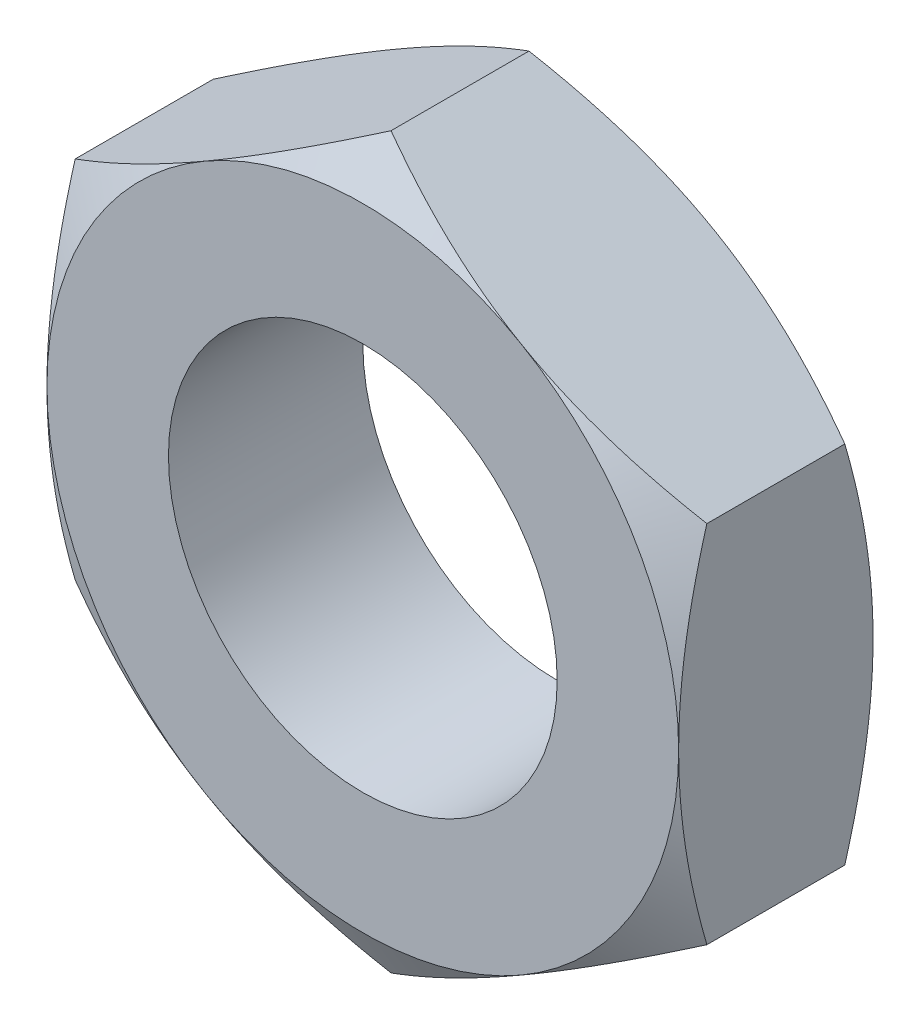
from build123d import *

# Parameters (mm, degrees)
SZKIC1_R                    = 4
DODANIE_WYCI_GNI_CIE1_DEPTH = 4


with BuildPart() as part:
    # Szkic1 → Dodanie-wyciągnięcie1 (new body)
    with BuildSketch(Plane.XY):
        Polygon((6.5, 3.75277675), (0, 7.505553499), (-6.5, 3.75277675), (-6.5, -3.75277675), (0, -7.505553499), (6.5, -3.75277675), align=None)
        Circle(SZKIC1_R, mode=Mode.SUBTRACT)
    extrude(amount=DODANIE_WYCI_GNI_CIE1_DEPTH)

    # Szkic2 → Wycięcie-obrót1 (revolve, cut)
    with BuildSketch(Plane(origin=(0, 0, 0), x_dir=(1, 0, 0), z_dir=(0, 1, 0))):
        Polygon((-9.964101615, -4), (-6.5, -4), (-9.964101615, -2), align=None)
        Polygon((-9.964101615, -2), (-6.5, 0), (-9.964101615, 0), align=None)
    revolve(axis=Axis((0, 0, 9.891098034), (0, 0, -1)), mode=Mode.SUBTRACT)


solid = part.part
